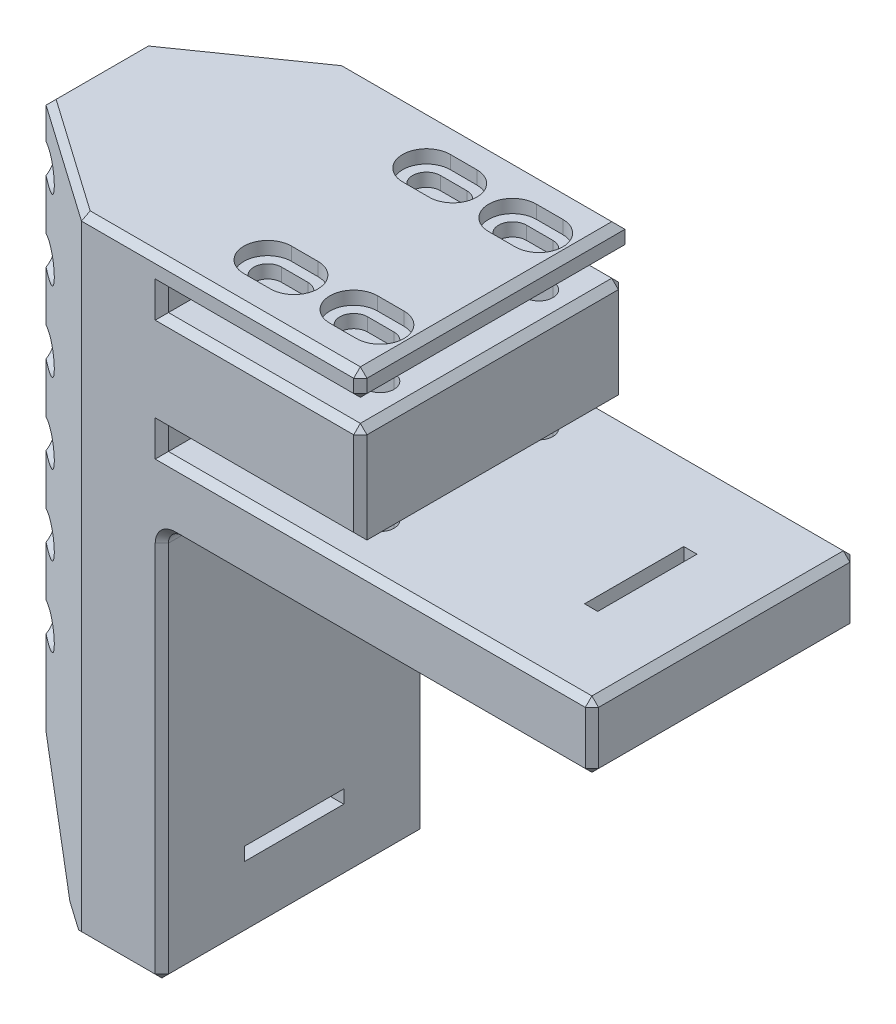
from build123d import *

# Parameters (mm, degrees)
BOSS_EXTRUDE1_DEPTH     = 40
CUT_EXTRUDE1_DEPTH      = 182
CUT_SWEEP1_PROFILE_R    = 2.5
LPATTERN1_COUNT         = 6
LPATTERN1_PITCH         = 12
CUT_EXTRUDE6_DEPTH      = 105
CHAMFER1_SIZE           = 1
CUT_EXTRUDE2_START      = -18.18
CUT_EXTRUDE2_DEPTH      = 90
CUT_EXTRUDE2_DEPTH_BACK = 10
SKETCH60_W              = 15
SKETCH60_H              = 2
CUT_EXTRUDE7_DEPTH      = 42
CUT_EXTRUDE10_DEPTH     = 121
SKETCH77_W              = 2
SKETCH77_H              = 15
CUT_EXTRUDE11_DEPTH     = 121
CUT_EXTRUDE13_DEPTH     = 2
CUT_EXTRUDE14_START     = -35.58
CUT_EXTRUDE14_DEPTH     = 4


with BuildPart() as part:
    # Sketch1 → Boss-Extrude1 (new body)
    with BuildSketch(Plane.XY):
        with BuildLine():
            Line((-15, 10.79), (15, 10.79))
            Line((15, 10.79), (15, 14.79))
            Line((15, 14.79), (-45, 14.79))
            Line((-45, 14.79), (-45, -80.21))
            Line((-45, -80.21), (-15, -80.21))
            Line((-15, -80.21), (-15, -22.79))
            ThreePointArc((-15, -22.79), (-14.414213562, -21.375786438), (-13, -20.79))
            Line((-13, -20.79), (50, -20.79))
            Line((50, -20.79), (50, -10.79))
            Line((50, -10.79), (-15, -10.79))
            Line((-15, -10.79), (-15, -7.39))
            Line((-15, -7.39), (15, -7.39))
            Line((15, -7.39), (15, 7.39))
            Line((15, 7.39), (-15, 7.39))
            Line((-15, 7.39), (-15, 10.79))
        make_face()
    extrude(amount=BOSS_EXTRUDE1_DEPTH)

    # Sketch3 → Cut-Extrude1 (cut)
    with BuildSketch(Plane(origin=(0, 14.79, 0), x_dir=(1, 0, 0), z_dir=(0, 1, 0))):
        Polygon((-43.354771646, -40), (-45, -38.931576215), (-45, -40), align=None)
        Polygon((-45, 0), (-43.354771646, 0), (-45, -1.068423785), align=None)
    extrude(amount=-CUT_EXTRUDE1_DEPTH, mode=Mode.SUBTRACT)

    # Cut-Sweep1: sweep along a path in Sketch2
    with BuildLine(Plane(origin=(0, 6.79, 0), x_dir=(1, 0, 0), z_dir=(0, 1, 0))) as cut_sweep1_path:
        CenterArc((-45, -20), 8.7, 0, 360)
    # Cut-Sweep1 profile (on start of the path) → Cut-Sweep1 (sweep, cut)
    with BuildSketch(Plane(origin=(-36.3, 6.79, 20), x_dir=(-1, 0, 0), z_dir=(0, 0, -1))):
        Circle(CUT_SWEEP1_PROFILE_R)
    cut_sweep1 = sweep(path=cut_sweep1_path.line, mode=Mode.SUBTRACT)

    # LPattern1: Cut-Sweep1 ×6
    with Locations(*[(0, -i * LPATTERN1_PITCH, 0) for i in range(1, LPATTERN1_COUNT)]):
        add(cut_sweep1, mode=Mode.SUBTRACT)

    # Sketch51 → Cut-Extrude6 (cut)
    with BuildSketch(Plane(origin=(0, 14.79, 0), x_dir=(1, 0, 0), z_dir=(0, 1, 0))):
        Polygon((-45, -12.5), (-27.148149916, 0), (-43.354771646, 0), (-45, -1.068423785), align=None)
        Polygon((-43.354771646, -40), (-27.148149916, -40), (-45, -27.5), (-45, -38.931576215), align=None)
    extrude(amount=-CUT_EXTRUDE6_DEPTH, mode=Mode.SUBTRACT)

    # Chamfer1
    chamfer1_edges = [part.edges().sort_by_distance(p)[0] for p in [
        (15, 10.79, 20),
        (0, 10.79, 0),
        (0, 10.79, 40),
        (-15, 9.09, 0),
        (-15, 9.09, 40),
        (15, 14.79, 20),
        (15, 12.79, 40),
        (0, 7.39, 0),
        (15, 0, 0),
        (0, -7.39, 0),
        (-15, -9.09, 0),
        (17.5, -10.79, 0),
        (50, -15.79, 0),
        (18.5, -20.79, 0),
        (-14.414213562, -21.375786438, 0),
        (-15, -51.5, 0),
        (-21.074074958, -80.21, 0),
        (-6.074074958, 14.79, 0),
        (0, 7.39, 40),
        (15, 0, 40),
        (0, -7.39, 40),
        (-15, -9.09, 40),
        (17.5, -10.79, 40),
        (50, -15.79, 40),
        (18.5, -20.79, 40),
        (-14.414213562, -21.375786438, 40),
        (-15, -51.5, 40),
        (-21.074074958, -80.21, 40),
        (-6.074074958, 14.79, 40),
        (15, 7.39, 20),
        (-36.074074958, 14.79, 6.25),
        (-45, 14.79, 20),
        (-36.074074958, 14.79, 33.75),
        (50, -10.79, 20),
        (50, -20.79, 20),
        (-15, -80.21, 20),
        (-45, -80.21, 20),
    ]]
    chamfer(chamfer1_edges, length=CHAMFER1_SIZE)

    # Sketch32 → Cut-Extrude2 (cut, two sides)
    with BuildSketch(Plane.XZ.offset(7.39).offset(CUT_EXTRUDE2_START)) as cut_extrude2_sk:
        with BuildLine():
            Line((-7, 34.1), (-3, 34.1))
            ThreePointArc((-3, 34.1), (-0.9, 32), (-3, 29.9))
            Line((-3, 29.9), (-7, 29.9))
            ThreePointArc((-7, 29.9), (-9.1, 32), (-7, 34.1))
        make_face()
        with BuildLine():
            Line((6, 34.1), (10, 34.1))
            ThreePointArc((10, 34.1), (12.1, 32), (10, 29.9))
            Line((10, 29.9), (6, 29.9))
            ThreePointArc((6, 29.9), (3.9, 32), (6, 34.1))
        make_face()
        with BuildLine():
            Line((-7, 5.9), (-3, 5.9))
            ThreePointArc((-3, 5.9), (-0.9, 8), (-3, 10.1))
            Line((-3, 10.1), (-7, 10.1))
            ThreePointArc((-7, 10.1), (-9.1, 8), (-7, 5.9))
        make_face()
        with BuildLine():
            Line((6, 5.9), (10, 5.9))
            ThreePointArc((10, 5.9), (12.1, 8), (10, 10.1))
            Line((10, 10.1), (6, 10.1))
            ThreePointArc((6, 10.1), (3.9, 8), (6, 5.9))
        make_face()
    extrude(amount=CUT_EXTRUDE2_DEPTH, mode=Mode.SUBTRACT)
    extrude(cut_extrude2_sk.sketch, amount=-CUT_EXTRUDE2_DEPTH_BACK, mode=Mode.SUBTRACT)

    # Sketch60 → Cut-Extrude7 (cut)
    with BuildSketch(Plane(origin=(-15, 0, 0), x_dir=(0, 0, -1), z_dir=(1, 0, 0))):
        with Locations((-20, -69.21)):
            Rectangle(SKETCH60_W, SKETCH60_H)
    extrude(amount=-CUT_EXTRUDE7_DEPTH, mode=Mode.SUBTRACT)

    # Sketch76 → Cut-Extrude10 (cut)
    with BuildSketch(Plane.XY.offset(40)):
        Polygon((-45, -68.21), (-26.02448376, -87.18551624), (-45, -87.18551624), align=None)
    extrude(amount=-CUT_EXTRUDE10_DEPTH, mode=Mode.SUBTRACT)

    # Sketch77 → Cut-Extrude11 (cut)
    with BuildSketch(Plane.XZ.offset(20.79)):
        with Locations((37.38320577, 20)):
            Rectangle(SKETCH77_W, SKETCH77_H)
    extrude(amount=-CUT_EXTRUDE11_DEPTH, mode=Mode.SUBTRACT)

    # Sketch79 → Cut-Extrude13 (cut)
    with BuildSketch(Plane(origin=(0, 14.79, 0), x_dir=(1, 0, 0), z_dir=(0, 1, 0))):
        with BuildLine():
            Line((-7, -4.4), (-3, -4.4))
            ThreePointArc((-3, -4.4), (0.6, -8), (-3, -11.6))
            Line((-3, -11.6), (-7, -11.6))
            ThreePointArc((-7, -11.6), (-10.6, -8), (-7, -4.4))
        make_face()
        with BuildLine():
            Line((6, -4.4), (10, -4.4))
            ThreePointArc((10, -4.4), (13.6, -8), (10, -11.6))
            Line((10, -11.6), (6, -11.6))
            ThreePointArc((6, -11.6), (2.4, -8), (6, -4.4))
        make_face()
        with BuildLine():
            Line((-7, -35.6), (-3, -35.6))
            ThreePointArc((-3, -35.6), (0.6, -32), (-3, -28.4))
            Line((-3, -28.4), (-7, -28.4))
            ThreePointArc((-7, -28.4), (-10.6, -32), (-7, -35.6))
        make_face()
        with BuildLine():
            Line((6, -35.6), (10, -35.6))
            ThreePointArc((10, -35.6), (13.6, -32), (10, -28.4))
            Line((10, -28.4), (6, -28.4))
            ThreePointArc((6, -28.4), (2.4, -32), (6, -35.6))
        make_face()
    extrude(amount=-CUT_EXTRUDE13_DEPTH, mode=Mode.SUBTRACT)

    # Sketch79_2 → Cut-Extrude14 (cut)
    with BuildSketch(Plane(origin=(0, 14.79, 0), x_dir=(1, 0, 0), z_dir=(0, 1, 0)).offset(CUT_EXTRUDE14_START)):
        with BuildLine():
            Line((-7, -4.4), (-3, -4.4))
            ThreePointArc((-3, -4.4), (0.6, -8), (-3, -11.6))
            Line((-3, -11.6), (-7, -11.6))
            ThreePointArc((-7, -11.6), (-10.6, -8), (-7, -4.4))
        make_face()
        with BuildLine():
            Line((6, -4.4), (10, -4.4))
            ThreePointArc((10, -4.4), (13.6, -8), (10, -11.6))
            Line((10, -11.6), (6, -11.6))
            ThreePointArc((6, -11.6), (2.4, -8), (6, -4.4))
        make_face()
        with BuildLine():
            Line((-7, -35.6), (-3, -35.6))
            ThreePointArc((-3, -35.6), (0.6, -32), (-3, -28.4))
            Line((-3, -28.4), (-7, -28.4))
            ThreePointArc((-7, -28.4), (-10.6, -32), (-7, -35.6))
        make_face()
        with BuildLine():
            Line((6, -35.6), (10, -35.6))
            ThreePointArc((10, -35.6), (13.6, -32), (10, -28.4))
            Line((10, -28.4), (6, -28.4))
            ThreePointArc((6, -28.4), (2.4, -32), (6, -35.6))
        make_face()
    extrude(amount=CUT_EXTRUDE14_DEPTH, mode=Mode.SUBTRACT)


solid = part.part
